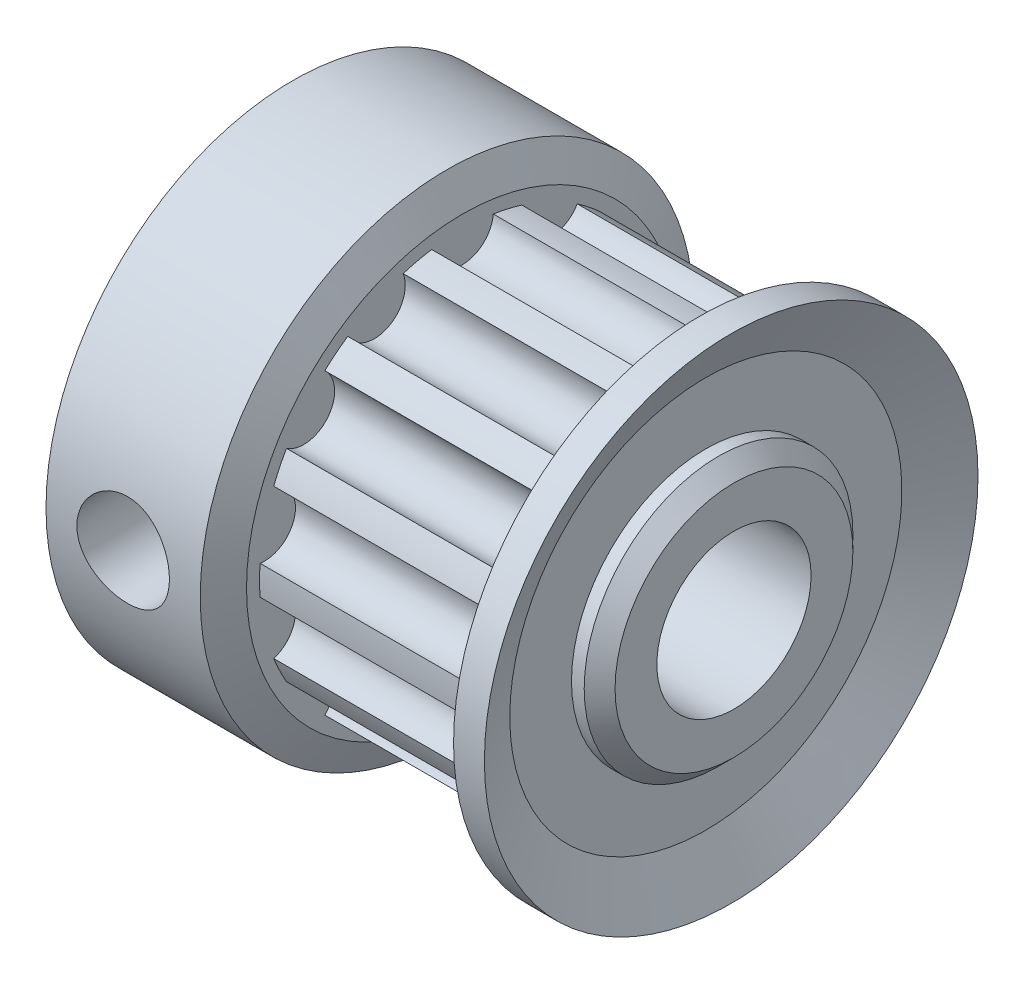
from build123d import *

# Parameters (mm, degrees)
SKETCH2_R          = 2.5
CUT_EXTRUDE1_DEPTH = 15.8
SKETCH3_R          = 1
CUT_EXTRUDE2_DEPTH = 7
SKETCH4_R          = 1.5
CUT_EXTRUDE3_DEPTH = 9


with BuildPart() as part:
    # Sketch1 → Revolve1 (revolve)
    with BuildSketch(Plane.XY):
        with BuildLine():
            Line((0, 7), (0, 3.9))
            ThreePointArc((0, 3.9), (0.029289322, 3.829289322), (0.1, 3.8))
            Line((0.1, 3.8), (0.3, 3.8))
            Line((0.3, 3.8), (0, 3.5))
            Line((0, 3.5), (0, 0))
            Line((0, 0), (14.8, 0))
            Line((14.8, 0), (14.8, 3.854253969))
            Line((14.8, 3.854253969), (14.3, 4.354253969))
            Line((14.3, 4.354253969), (13.887802139, 4.354253969))
            Line((13.887802139, 4.354253969), (13.887802139, 6.354253969))
            Line((13.887802139, 6.354253969), (14.710675154, 8))
            Line((14.710675154, 8), (13.710675154, 8))
            Line((13.710675154, 8), (13, 6.578649691))
            Line((13, 6.578649691), (6, 6.578649691))
            Line((6, 6.578649691), (6, 7))
            Line((6, 7), (5.5, 8))
            Line((5.5, 8), (0.5, 8))
            Line((0.5, 8), (0, 7))
        make_face()
    revolve(axis=Axis((0, 0, 0), (1, 0, 0)))

    # Sketch2 → Cut-Extrude1 (cut, through all)
    with BuildSketch(Plane(origin=(14.8, 0, 0), x_dir=(0, 0, -1), z_dir=(1, 0, 0))):
        Circle(SKETCH2_R)
    extrude(amount=-CUT_EXTRUDE1_DEPTH, mode=Mode.SUBTRACT)

    # Sketch3 → Cut-Extrude2 (cut)
    with BuildSketch(Plane(origin=(6, 0, 0), x_dir=(0, 0, -1), z_dir=(1, 0, 0))):
        with Locations((2.854369126, 5.927158565)):
            Circle(SKETCH3_R)
        with Locations((0, 6.578649691)):
            Circle(SKETCH3_R)
        with Locations((5.143395441, 4.101720992)):
            Circle(SKETCH3_R)
        with Locations((6.413709208, 1.463887273)):
            Circle(SKETCH3_R)
        with Locations((6.413709208, -1.463887273)):
            Circle(SKETCH3_R)
        with Locations((5.143395441, -4.101720992)):
            Circle(SKETCH3_R)
        with Locations((2.854369126, -5.927158565)):
            Circle(SKETCH3_R)
        with Locations((0, -6.578649691)):
            Circle(SKETCH3_R)
        with Locations((-2.854369126, -5.927158565)):
            Circle(SKETCH3_R)
        with Locations((-5.143395441, -4.101720992)):
            Circle(SKETCH3_R)
        with Locations((-6.413709208, -1.463887273)):
            Circle(SKETCH3_R)
        with Locations((-6.413709208, 1.463887273)):
            Circle(SKETCH3_R)
        with Locations((-5.143395441, 4.101720992)):
            Circle(SKETCH3_R)
        with Locations((-2.854369126, 5.927158565)):
            Circle(SKETCH3_R)
    extrude(amount=CUT_EXTRUDE2_DEPTH, mode=Mode.SUBTRACT)

    # Sketch4 → Cut-Extrude3 (cut, through all)
    with BuildSketch(Plane.XY):
        with Locations((3, 0)):
            Circle(SKETCH4_R)
    extrude(amount=CUT_EXTRUDE3_DEPTH, mode=Mode.SUBTRACT)


solid = part.part
